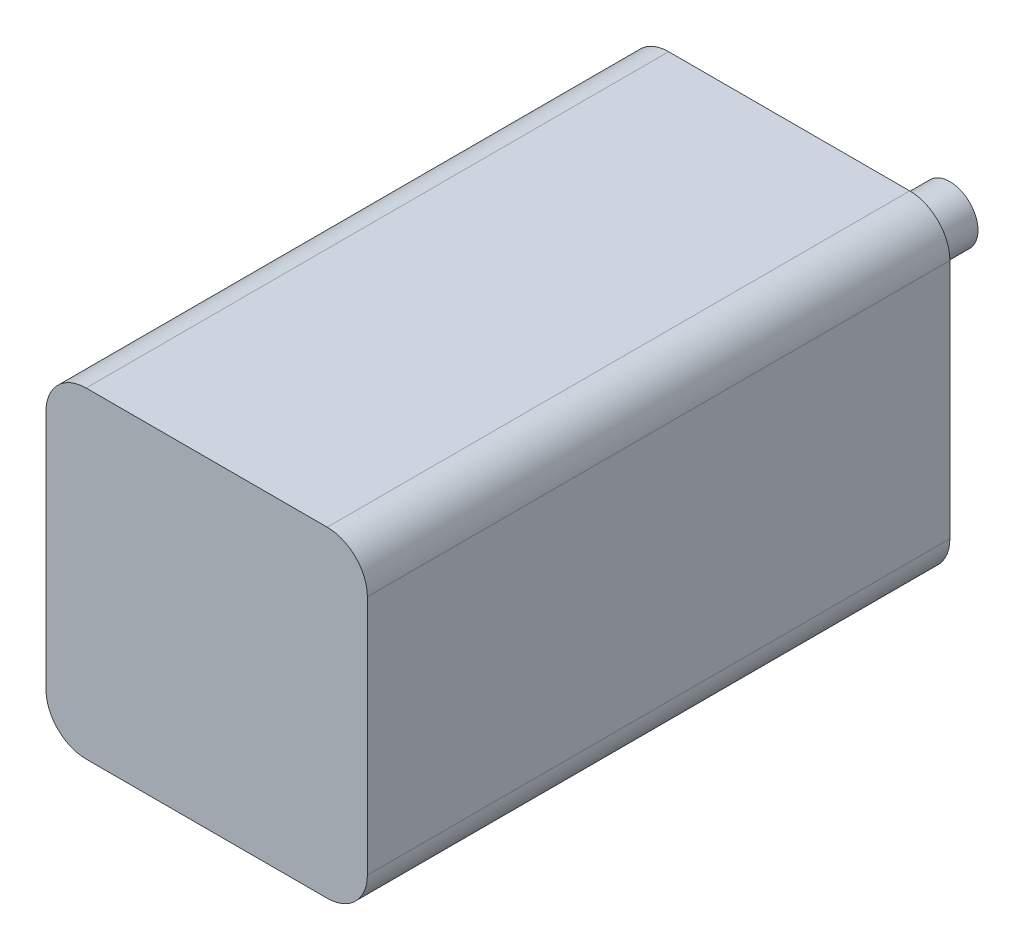
from build123d import *

# Parameters (mm, degrees)
SKETCH_1_W               = 80
SKETCH_1_H               = 80
EXTRUDE_1_DEPTH          = 145
FILLET_1_R               = 10
SKETCH_2_R               = 7
EXTRUDE_2_DEPTH          = 40
SKETCH_3_R               = 3.271360977
CUT_EXTRUDE_1_DEPTH      = 10
PATTERN_CIRCULAR_1_COUNT = 3


with BuildPart() as part:
    # Эскиз1 → Бобышка-Вытянуть1 (new body)
    with BuildSketch(Plane.XY):
        with Locations((-16.484717947, -21.221052632)):
            Rectangle(SKETCH_1_W, SKETCH_1_H)
    extrude(amount=EXTRUDE_1_DEPTH)

    # Скругление1
    fillet_1_edges = [part.edges().sort_by_distance(p)[0] for p in [
        (-56.484717947, 18.778947368, 72.5),
        (23.515282053, 18.778947368, 72.5),
        (23.515282053, -61.221052632, 72.5),
        (-56.484717947, -61.221052632, 72.5),
    ]]
    fillet(fillet_1_edges, radius=FILLET_1_R)

    # Эскиз2 → Бобышка-Вытянуть2 (add)
    with BuildSketch(Plane(origin=(0, 0, 0), x_dir=(-1, 0, 0), z_dir=(0, 0, -1))):
        with Locations((16.484717947, -21.221052632)):
            Circle(SKETCH_2_R)
    extrude(amount=EXTRUDE_2_DEPTH)

    # Эскиз3 → Вырез-Вытянуть1 (cut)
    with BuildSketch(Plane(origin=(0, 0, 0), x_dir=(-1, 0, 0), z_dir=(0, 0, -1))):
        with Locations((17.021835437, 8.778947368)):
            Circle(SKETCH_3_R)
    cut_extrude_1 = extrude(amount=-CUT_EXTRUDE_1_DEPTH, mode=Mode.SUBTRACT)

    # Круговой массив1: Вырез-Вытянуть1 ×3 about axis
    pattern_circular_1_axis = Axis((-16.484717947, -21.221052632, 0), (0, 0, 1))
    for i in range(1, PATTERN_CIRCULAR_1_COUNT):
        add(cut_extrude_1.rotate(pattern_circular_1_axis, i * 360 / PATTERN_CIRCULAR_1_COUNT), mode=Mode.SUBTRACT)


solid = part.part
